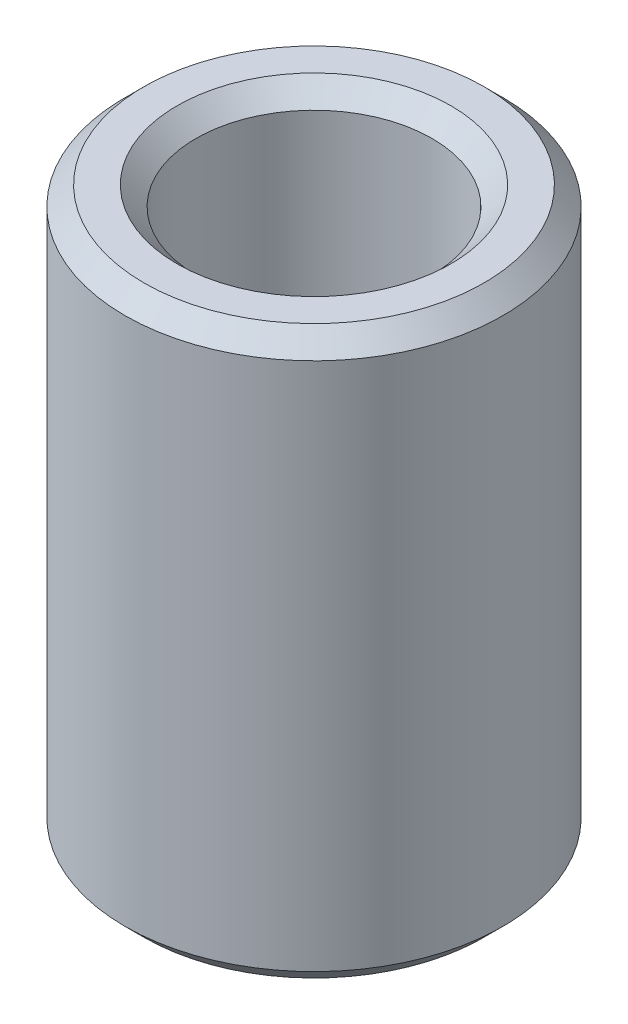
from build123d import *

# Parameters (mm, degrees)
SKETCH1_R           = 20
SKETCH1_R_2         = 12.5
BOSS_EXTRUDE1_DEPTH = 30
CHAMFER1_SIZE       = 2
CHAMFER2_SIZE       = 2
CHAMFER3_SIZE       = 2
CHAMFER4_SIZE       = 2


with BuildPart() as part:
    # Sketch1 → Boss-Extrude1 (new body, symmetric)
    with BuildSketch(Plane(origin=(0, 0, 0), x_dir=(1, 0, 0), z_dir=(0, 1, 0))):
        Circle(SKETCH1_R)
        Circle(SKETCH1_R_2, mode=Mode.SUBTRACT)
    extrude(amount=BOSS_EXTRUDE1_DEPTH, both=True)

    # Chamfer1
    chamfer1_edges = [part.edges().sort_by_distance(p)[0] for p in [
        (-20, 30, 0),
    ]]
    chamfer(chamfer1_edges, length=CHAMFER1_SIZE)

    # Chamfer2
    chamfer2_edges = [part.edges().sort_by_distance(p)[0] for p in [
        (-12.5, 30, 0),
    ]]
    chamfer(chamfer2_edges, length=CHAMFER2_SIZE)

    # Chamfer3
    chamfer3_edges = [part.edges().sort_by_distance(p)[0] for p in [
        (-20, -30, 0),
    ]]
    chamfer(chamfer3_edges, length=CHAMFER3_SIZE)

    # Chamfer4
    chamfer4_edges = [part.edges().sort_by_distance(p)[0] for p in [
        (-12.5, -30, 0),
    ]]
    chamfer(chamfer4_edges, length=CHAMFER4_SIZE)


solid = part.part
